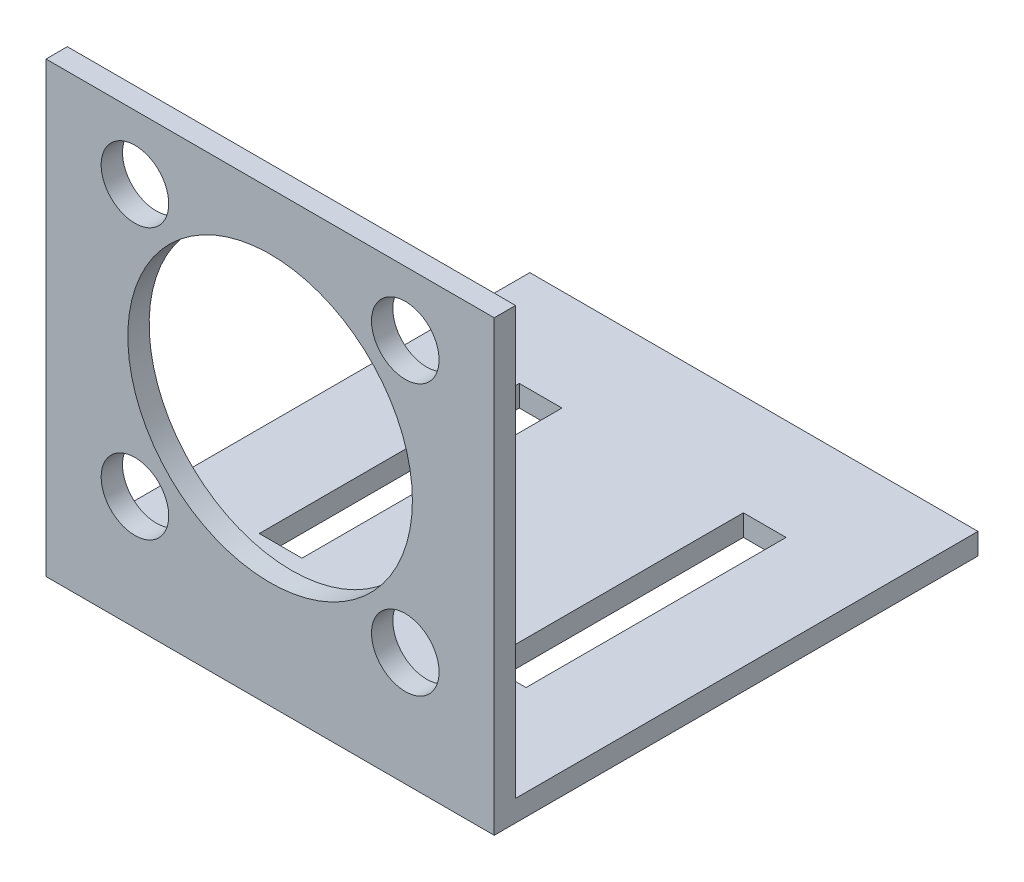
from build123d import *

# Parameters (mm, degrees)
BOSS_EXTRUDE1_DEPTH     = 63
SKETCH2_R               = 4.75
SKETCH2_R_2             = 20
CUT_EXTRUDE1_DEPTH      = 35.80267333
CUT_EXTRUDE1_DEPTH_BACK = 34.19732667
SKETCH3_W               = 6
SKETCH3_H               = 36.550616257
CUT_EXTRUDE2_DEPTH      = 4


with BuildPart() as part:
    # Sketch1 → Boss-Extrude1 (new body)
    with BuildSketch(Plane(origin=(0, 0, 0), x_dir=(0, 0, -1), z_dir=(1, 0, 0))):
        Polygon((-31.80267333, 29.42384106), (-31.80267333, -30.57615894), (33.19732667, -30.57615894), (33.19732667, -33.57615894), (-34.80267333, -33.57615894), (-34.80267333, 29.42384106), align=None)
    extrude(amount=BOSS_EXTRUDE1_DEPTH)

    # Sketch2 → Cut-Extrude1 (cut, two sides)
    with BuildSketch(Plane.XY) as cut_extrude1_sk:
        with Locations((50.5, -17.57615894)):
            Circle(SKETCH2_R)
        with Locations((50.5, 20.42384106)):
            Circle(SKETCH2_R)
        with Locations((12.5, -17.57615894)):
            Circle(SKETCH2_R)
        with Locations((12.5, 20.42384106)):
            Circle(SKETCH2_R)
        with Locations((31.5, 1.42384106)):
            Circle(SKETCH2_R_2)
    extrude(amount=CUT_EXTRUDE1_DEPTH, mode=Mode.SUBTRACT)
    extrude(cut_extrude1_sk.sketch, amount=-CUT_EXTRUDE1_DEPTH_BACK, mode=Mode.SUBTRACT)

    # Sketch3 → Cut-Extrude2 (cut, through all)
    with BuildSketch(Plane(origin=(0, -30.57615894, 0), x_dir=(1, 0, 0), z_dir=(0, 1, 0))):
        with Locations((15.75, 0.697326671)):
            Rectangle(SKETCH3_W, SKETCH3_H)
        with Locations((47.25, 0.697326671)):
            Rectangle(SKETCH3_W, SKETCH3_H)
    extrude(amount=-CUT_EXTRUDE2_DEPTH, mode=Mode.SUBTRACT)


solid = part.part
